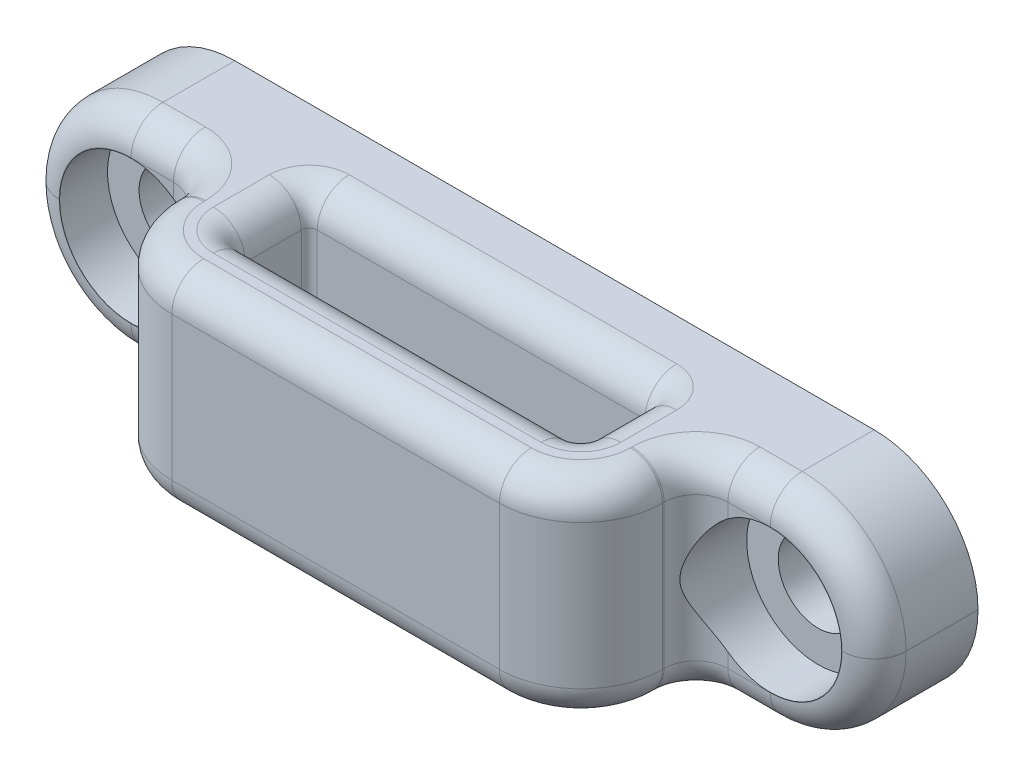
from build123d import *

# Parameters (mm, degrees)
STRAPSURROUNDINGMEAT_EXTRUDE_START = -6.505
STRAPSURROUNDINGMEAT_EXTRUDE_DEPTH = 13.01
MOUNTINGWINGS_EXTRUDE_DEPTH        = 6.5
STRAPSLOT_EXTRUDE_DEPTH            = 7.505
STRAPSLOT_EXTRUDE_DEPTH_BACK       = 7.505
SLOTBUGLINGFILLET_R                = 2
COSMETICFILLET_R                   = 2
SCREWCLEARANCEHOLES_SKETCH_R       = 2.5
SCREWCLEARANCEHOLES_CUT_DEPTH      = 14.7
SCREWHEADCLEARANCEHOLES_CUT_START  = 3.5
SCREWHEADCLEARANCEHOLES_SKETCH_R   = 4.475
SCREWHEADCLEARANCEHOLES_CUT_DEPTH  = 11.2


with BuildPart() as part:
    # strapSlotWalls_sketch → strapSurroundingMeat_extrude (new body)
    with BuildSketch(Plane(origin=(0, 0, 0), x_dir=(1, 0, 0), z_dir=(0, 1, 0)).offset(STRAPSURROUNDINGMEAT_EXTRUDE_START)):
        with BuildLine():
            Line((-10.25, -13.7), (10.25, -13.7))
            ThreePointArc((10.25, -13.7), (13.856244584, -12.206244584), (15.35, -8.6))
            Line((15.35, -8.6), (15.35, 0))
            Line((15.35, 0), (-15.35, 0))
            Line((-15.35, 0), (-15.35, -8.6))
            ThreePointArc((-15.35, -8.6), (-13.856244584, -12.206244584), (-10.25, -13.7))
        make_face()
    extrude(amount=STRAPSURROUNDINGMEAT_EXTRUDE_DEPTH)

    # mountingWings_sketch → mountingWings_extrude (add)
    with BuildSketch(Plane.XY):
        with BuildLine():
            Line((-20, -6.505), (20, -6.505))
            ThreePointArc((20, -6.505), (24.596194078, -4.601194078), (26.5, -0.005))
            Line((26.5, -0.005), (26.5, 0.005))
            ThreePointArc((26.5, 0.005), (24.596194078, 4.601194078), (20, 6.505))
            Line((20, 6.505), (-20, 6.505))
            ThreePointArc((-20, 6.505), (-24.596194078, 4.601194078), (-26.5, 0.005))
            Line((-26.5, 0.005), (-26.5, -0.005))
            ThreePointArc((-26.5, -0.005), (-24.596194078, -4.601194078), (-20, -6.505))
        make_face()
    extrude(amount=MOUNTINGWINGS_EXTRUDE_DEPTH)

    # strapSlot_sketch → strapSlot_extrude (cut, two sides)
    with BuildSketch(Plane(origin=(0, 0, 0), x_dir=(1, 0, 0), z_dir=(0, 1, 0))) as strapslot_extrude_sk:
        with BuildLine():
            Line((-10.25, -9.1), (10.25, -9.1))
            ThreePointArc((10.25, -9.1), (10.603553391, -8.953553391), (10.75, -8.6))
            Line((10.75, -8.6), (10.75, -5.1))
            ThreePointArc((10.75, -5.1), (10.603553391, -4.746446609), (10.25, -4.6))
            Line((10.25, -4.6), (-10.25, -4.6))
            ThreePointArc((-10.25, -4.6), (-10.603553391, -4.746446609), (-10.75, -5.1))
            Line((-10.75, -5.1), (-10.75, -8.6))
            ThreePointArc((-10.75, -8.6), (-10.603553391, -8.953553391), (-10.25, -9.1))
        make_face()
    extrude(amount=STRAPSLOT_EXTRUDE_DEPTH, mode=Mode.SUBTRACT)
    extrude(strapslot_extrude_sk.sketch, amount=-STRAPSLOT_EXTRUDE_DEPTH_BACK, mode=Mode.SUBTRACT)

    # slotBuglingFillet
    slotbuglingfillet_edges = [part.edges().sort_by_distance(p)[0] for p in [
        (10.603553391, -6.505, 8.953553391),
        (0, 6.505, 9.1),
        (-10.603553391, -6.505, 8.953553391),
        (-10.75, 6.505, 6.85),
        (-10.603553391, -6.505, 4.746446609),
        (0, 6.505, 4.6),
        (10.603553391, -6.505, 4.746446609),
        (10.75, 6.505, 6.85),
        (0, -6.505, 9.1),
        (-10.75, -6.505, 6.85),
        (0, -6.505, 4.6),
        (10.75, -6.505, 6.85),
        (10.603553391, 6.505, 8.953553391),
        (10.603553391, 6.505, 4.746446609),
        (-10.603553391, 6.505, 4.746446609),
        (-10.603553391, 6.505, 8.953553391),
    ]]
    fillet(slotbuglingfillet_edges, radius=SLOTBUGLINGFILLET_R)

    # cosmeticFillet
    cosmeticfillet_edges = [part.edges().sort_by_distance(p)[0] for p in [
        (-15.35, 6.505, 7.55),
        (-15.35, -6.505, 7.55),
        (-13.856244584, -6.505, 12.206244584),
        (17.675, -6.505, 6.5),
        (-17.675, -6.505, 6.5),
        (17.675, 6.505, 6.5),
        (-17.675, 6.505, 6.5),
        (24.596194078, -4.601194078, 6.5),
        (24.596194078, 4.601194078, 6.5),
        (-24.596194078, 4.601194078, 6.5),
        (-24.596194078, -4.601194078, 6.5),
        (0, -6.505, 13.7),
        (26.5, 0, 6.5),
        (13.856244584, -6.505, 12.206244584),
        (-26.5, 0, 6.5),
        (15.35, 0, 6.5),
        (-15.35, 0, 6.5),
        (13.856244584, 6.505, 12.206244584),
        (15.35, 6.505, 7.55),
        (-13.856244584, 6.505, 12.206244584),
        (0, 6.505, 13.7),
        (15.35, -6.505, 7.55),
    ]]
    fillet(cosmeticfillet_edges, radius=COSMETICFILLET_R)

    # screwClearanceHoles_sketch → screwClearanceHoles_cut (cut, through all)
    with BuildSketch(Plane.XY):
        with Locations((-20, 0)):
            Circle(SCREWCLEARANCEHOLES_SKETCH_R)
        with Locations((20, 0)):
            Circle(SCREWCLEARANCEHOLES_SKETCH_R)
    extrude(amount=SCREWCLEARANCEHOLES_CUT_DEPTH, mode=Mode.SUBTRACT)

    # screwHeadClearanceHoles_sketch → screwHeadClearanceHoles_cut (cut, through all)
    with BuildSketch(Plane.XY.offset(SCREWHEADCLEARANCEHOLES_CUT_START)):
        with Locations((-20, 0)):
            Circle(SCREWHEADCLEARANCEHOLES_SKETCH_R)
        with Locations((20, 0)):
            Circle(SCREWHEADCLEARANCEHOLES_SKETCH_R)
    extrude(amount=SCREWHEADCLEARANCEHOLES_CUT_DEPTH, mode=Mode.SUBTRACT)


solid = part.part
